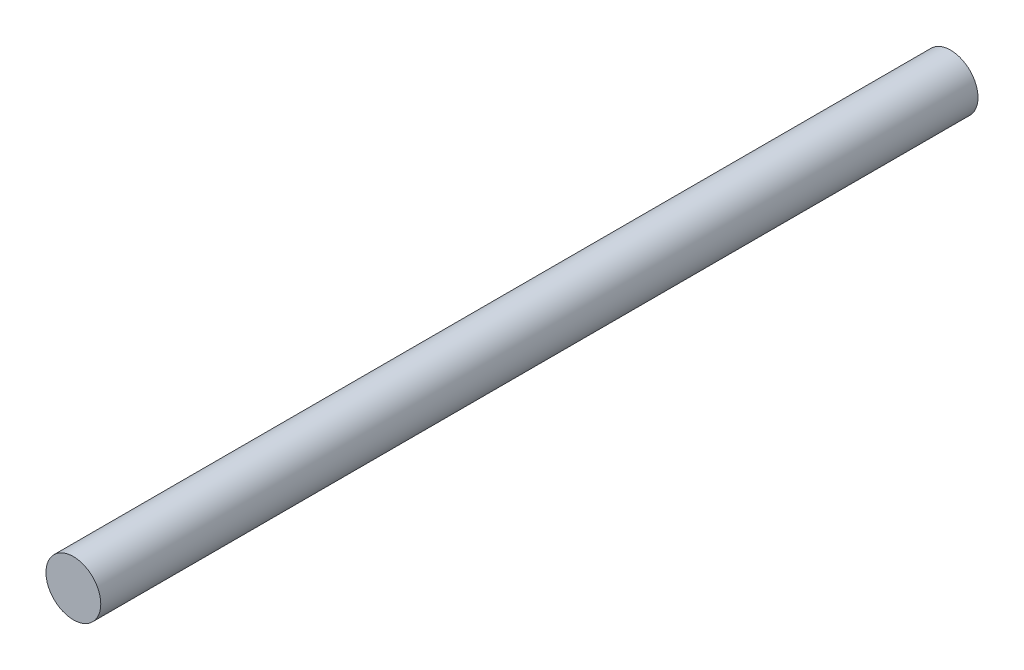
from build123d import *

# Parameters (mm, degrees)
SKETCH1_R           = 5
BOSS_EXTRUDE1_DEPTH = 160


with BuildPart() as part:
    # Sketch1 → Boss-Extrude1 (new body)
    with BuildSketch(Plane.XY):
        with Locations((-45.925011204, -30.390461356)):
            Circle(SKETCH1_R)
    extrude(amount=BOSS_EXTRUDE1_DEPTH)


solid = part.part
